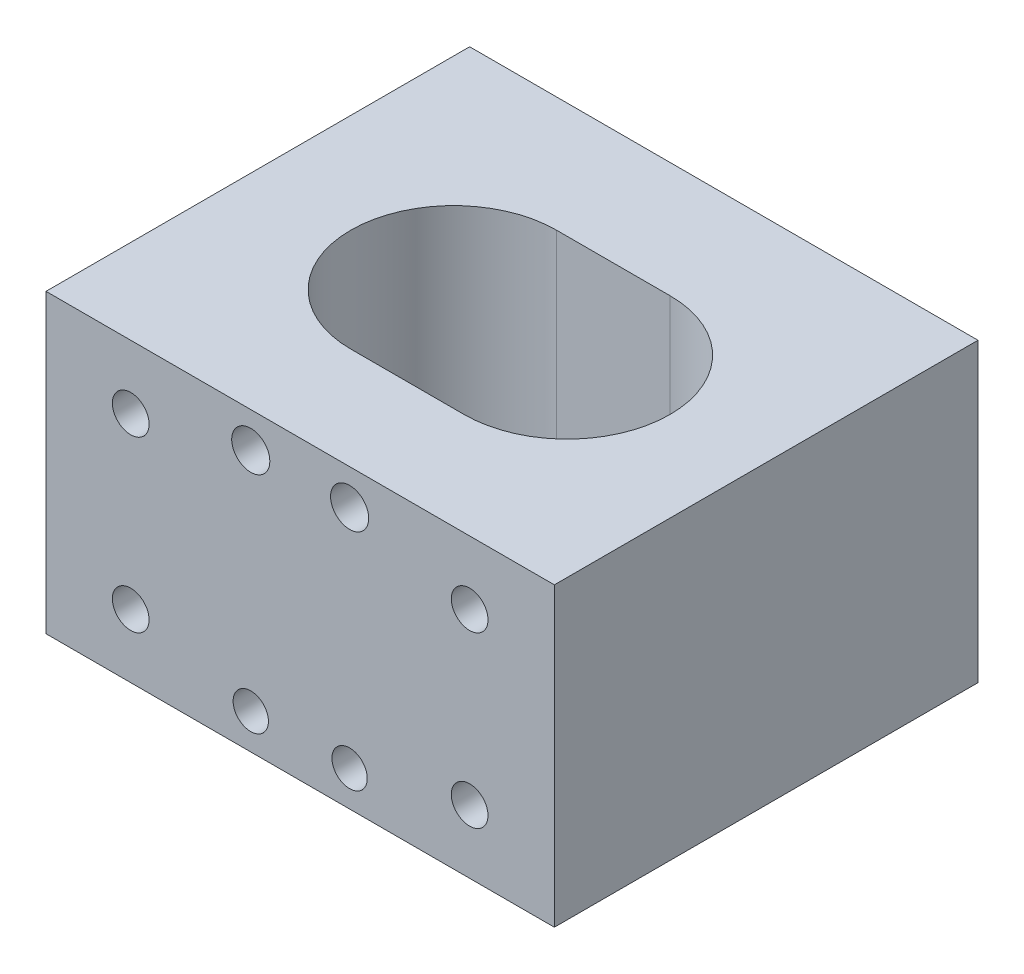
from build123d import *

# Parameters (mm, degrees)
SKETCH_1_W          = 36
SKETCH_1_H          = 21
SKETCH_1_R          = 1.25
SKETCH_1_R_2        = 1.3
SKETCH_1_R_3        = 1.35
EXTRUDE_1_DEPTH     = 30
SKETCH_1_5_R        = 1.3
SKETCH_1_5_R_2      = 1.35
SKETCH_1_5_R_3      = 1.25
CUT_EXTRUDE_1_DEPTH = 4
CUT_EXTRUDE_START   = 30
SKETCH_1_6_R        = 1.35
SKETCH_1_6_R_2      = 1.3
SKETCH_1_6_R_3      = 1.25
CUT_EXTRUDE_2_DEPTH = 4
CUT_EXTRUDE1_DEPTH  = 30


with BuildPart() as part:
    # 스케치1 → 보스-돌출1 (new body)
    with BuildSketch(Plane.XY):
        Rectangle(SKETCH_1_W, SKETCH_1_H)
        with Locations((-3.5, -8)):
            Circle(SKETCH_1_R, mode=Mode.SUBTRACT)
        with Locations((3.5, -8)):
            Circle(SKETCH_1_R, mode=Mode.SUBTRACT)
        with Locations((-12, 6)):
            Circle(SKETCH_1_R_2, mode=Mode.SUBTRACT)
        with Locations((12, 6)):
            Circle(SKETCH_1_R_2, mode=Mode.SUBTRACT)
        with Locations((12, -6)):
            Circle(SKETCH_1_R_2, mode=Mode.SUBTRACT)
        with Locations((-12, -6)):
            Circle(SKETCH_1_R_2, mode=Mode.SUBTRACT)
        with Locations((3.5, 8)):
            Circle(SKETCH_1_R_3, mode=Mode.SUBTRACT)
        with Locations((-3.5, 8)):
            Circle(SKETCH_1_R_3, mode=Mode.SUBTRACT)
        with Locations((12, -6)):
            Circle(SKETCH_1_R_2)
        with Locations((3.5, -8)):
            Circle(SKETCH_1_R)
        with Locations((-3.5, -8)):
            Circle(SKETCH_1_R)
        with Locations((-12, -6)):
            Circle(SKETCH_1_R_2)
        with Locations((-12, 6)):
            Circle(SKETCH_1_R_2)
        with Locations((-3.5, 8)):
            Circle(SKETCH_1_R_3)
        with Locations((3.5, 8)):
            Circle(SKETCH_1_R_3)
        with Locations((12, 6)):
            Circle(SKETCH_1_R_2)
    extrude(amount=EXTRUDE_1_DEPTH)

    # 스케치1<5> → 컷-돌출1 (cut)
    with BuildSketch(Plane.XY):
        with Locations((12, 6)):
            Circle(SKETCH_1_5_R)
        with Locations((3.5, 8)):
            Circle(SKETCH_1_5_R_2)
        with Locations((-3.5, 8)):
            Circle(SKETCH_1_5_R_2)
        with Locations((-12, 6)):
            Circle(SKETCH_1_5_R)
        with Locations((-12, -6)):
            Circle(SKETCH_1_5_R)
        with Locations(Location((-3.5, -8, 0), (0, 0, 180))):
            Circle(SKETCH_1_5_R_3)
        with Locations((3.5, -8)):
            Circle(SKETCH_1_5_R_3)
        with Locations((12, -6)):
            Circle(SKETCH_1_5_R)
    extrude(amount=CUT_EXTRUDE_1_DEPTH, mode=Mode.SUBTRACT)

    # 스케치1<6> → 컷-돌출2 (cut)
    with BuildSketch(Plane.XY.offset(CUT_EXTRUDE_START)):
        with Locations((3.5, 8)):
            Circle(SKETCH_1_6_R)
        with Locations((12, 6)):
            Circle(SKETCH_1_6_R_2)
        with Locations((-3.5, 8)):
            Circle(SKETCH_1_6_R)
        with Locations((-12, 6)):
            Circle(SKETCH_1_6_R_2)
        with Locations((-12, -6)):
            Circle(SKETCH_1_6_R_2)
        with Locations(Location((-3.5, -8, 0), (0, 0, 180))):
            Circle(SKETCH_1_6_R_3)
        with Locations((3.5, -8)):
            Circle(SKETCH_1_6_R_3)
        with Locations((12, -6)):
            Circle(SKETCH_1_6_R_2)
    extrude(amount=-CUT_EXTRUDE_2_DEPTH, mode=Mode.SUBTRACT)

    # Sketch2 → Cut-Extrude1 (cut)
    with BuildSketch(Plane(origin=(0, 10.5, 0), x_dir=(1, 0, 0), z_dir=(0, 1, 0))):
        with BuildLine():
            Line((-3.671911896, -8.172290791), (4.36058603, -8.172290791))
            ThreePointArc((4.36058603, -8.172290791), (11.649583923, -15.461288684), (4.36058603, -22.750286576))
            Line((4.36058603, -22.750286576), (-3.671911896, -22.750286576))
            ThreePointArc((-3.671911896, -22.750286576), (-10.960909789, -15.461288684), (-3.671911896, -8.172290791))
        make_face()
    extrude(amount=-CUT_EXTRUDE1_DEPTH, mode=Mode.SUBTRACT)


solid = part.part
